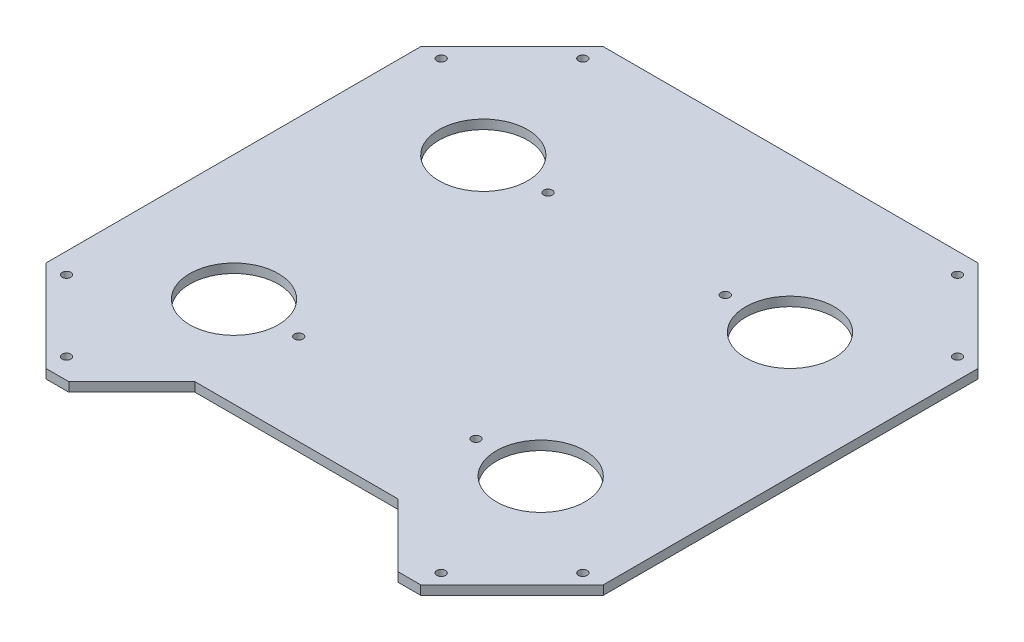
from build123d import *

# Parameters (mm, degrees)
SKETCH1_R           = 48.5
SKETCH1_R_2         = 4.7625
BOSS_EXTRUDE1_DEPTH = 10
CUT_EXTRUDE1_DEPTH  = 5000
SKETCH3_R           = 4.7625
CUT_EXTRUDE2_DEPTH  = 5000


with BuildPart() as part:
    # Sketch1 → Boss-Extrude1 (new body)
    with BuildSketch(Plane(origin=(0, 0, 0), x_dir=(1, 0, 0), z_dir=(0, 1, 0))):
        Polygon((205, 610), (-205, 610), (-305, 510), (-305, 100), (-205, 0), (205, 0), (305, 100), (305, 510), align=None)
        with Locations((-167.82128445, 168.589357775)):
            Circle(SKETCH1_R, mode=Mode.SUBTRACT)
        with Locations((-97, 168.589357775)):
            Circle(SKETCH1_R_2, mode=Mode.SUBTRACT)
        with Locations((97, 168.589357775)):
            Circle(SKETCH1_R_2, mode=Mode.SUBTRACT)
        with Locations((167.82128445, 168.589357775)):
            Circle(SKETCH1_R, mode=Mode.SUBTRACT)
        with Locations((-167.82128445, 441.410642225)):
            Circle(SKETCH1_R, mode=Mode.SUBTRACT)
        with Locations((-97, 441.410642225)):
            Circle(SKETCH1_R_2, mode=Mode.SUBTRACT)
        with Locations((97, 441.410642225)):
            Circle(SKETCH1_R_2, mode=Mode.SUBTRACT)
        with Locations((167.82128445, 441.410642225)):
            Circle(SKETCH1_R, mode=Mode.SUBTRACT)
    extrude(amount=BOSS_EXTRUDE1_DEPTH)

    # Sketch2 → Cut-Extrude1 (cut)
    with BuildSketch(Plane(origin=(0, 10, 0), x_dir=(1, 0, 0), z_dir=(0, 1, 0))):
        Polygon((-111, 69), (-180, 0), (180, 0), (111, 69), align=None)
    extrude(amount=-CUT_EXTRUDE1_DEPTH, mode=Mode.SUBTRACT)

    # Sketch3 → Cut-Extrude2 (cut)
    with BuildSketch(Plane(origin=(0, 10, 0), x_dir=(1, 0, 0), z_dir=(0, 1, 0))):
        with Locations((-205, 22.45771137)):
            Circle(SKETCH3_R)
        with Locations((205, 22.45771137)):
            Circle(SKETCH3_R)
        with Locations((-282.54228863, 100)):
            Circle(SKETCH3_R)
        with Locations((282.54228863, 100)):
            Circle(SKETCH3_R)
        with Locations((282.54228863, 510)):
            Circle(SKETCH3_R)
        with Locations((205, 587.54228863)):
            Circle(SKETCH3_R)
        with Locations((-205, 587.54228863)):
            Circle(SKETCH3_R)
        with Locations((-282.54228863, 510)):
            Circle(SKETCH3_R)
    extrude(amount=-CUT_EXTRUDE2_DEPTH, mode=Mode.SUBTRACT)


solid = part.part
